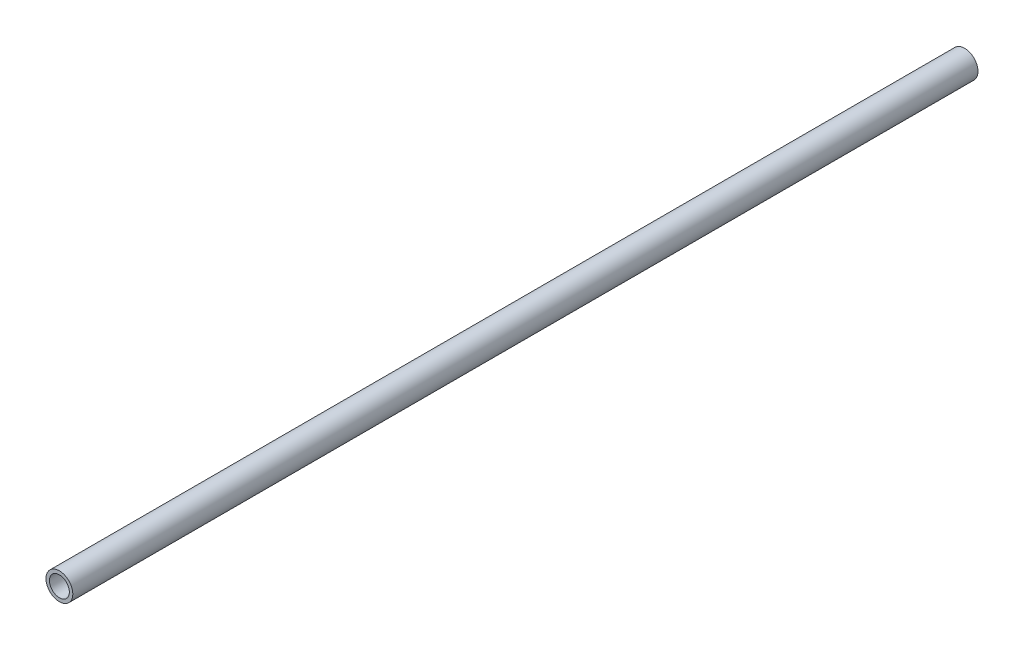
from build123d import *

# Parameters (mm, degrees)
SKETCH1_R           = 10.668
SKETCH1_R_2         = 7.8994
EXTRUDE_THIN1_DEPTH = 360


with BuildPart() as part:
    # Sketch1 → Extrude-Thin1 (new body, symmetric)
    with BuildSketch(Plane.XY):
        Circle(SKETCH1_R)
        Circle(SKETCH1_R_2, mode=Mode.SUBTRACT)
    extrude(amount=EXTRUDE_THIN1_DEPTH, both=True)


solid = part.part
